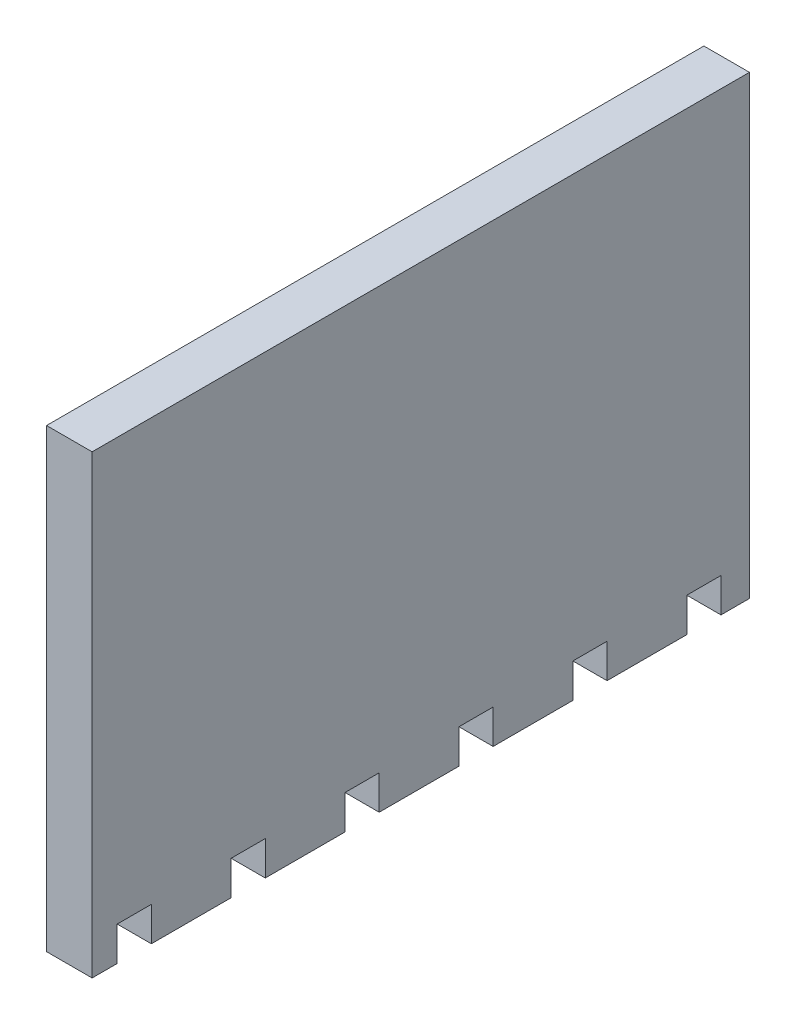
from build123d import *

# Parameters (mm, degrees)
SKETCH1_W           = 20
SKETCH1_H           = 200
BOSS_EXTRUDE1_DEPTH = 288.5
SKETCH2_W           = 15
SKETCH2_H           = 15
CUT_EXTRUDE1_DEPTH  = 20


with BuildPart() as part:
    # Sketch1 → Boss-Extrude1 (new body)
    with BuildSketch(Plane.XY):
        with Locations((0, -100)):
            Rectangle(SKETCH1_W, SKETCH1_H)
    extrude(amount=BOSS_EXTRUDE1_DEPTH)

    # Sketch2 → Cut-Extrude1 (cut)
    with BuildSketch(Plane(origin=(10, 0, 0), x_dir=(0, 0, -1), z_dir=(1, 0, 0))):
        with Locations((-270, -192.5)):
            Rectangle(SKETCH2_W, SKETCH2_H)
        with Locations((-220, -192.5)):
            Rectangle(SKETCH2_W, SKETCH2_H)
        with Locations((-170, -192.5)):
            Rectangle(SKETCH2_W, SKETCH2_H)
        with Locations((-120, -192.5)):
            Rectangle(SKETCH2_W, SKETCH2_H)
        with Locations((-70, -192.5)):
            Rectangle(SKETCH2_W, SKETCH2_H)
        with Locations((-20, -192.5)):
            Rectangle(SKETCH2_W, SKETCH2_H)
    extrude(amount=-CUT_EXTRUDE1_DEPTH, mode=Mode.SUBTRACT)


solid = part.part
